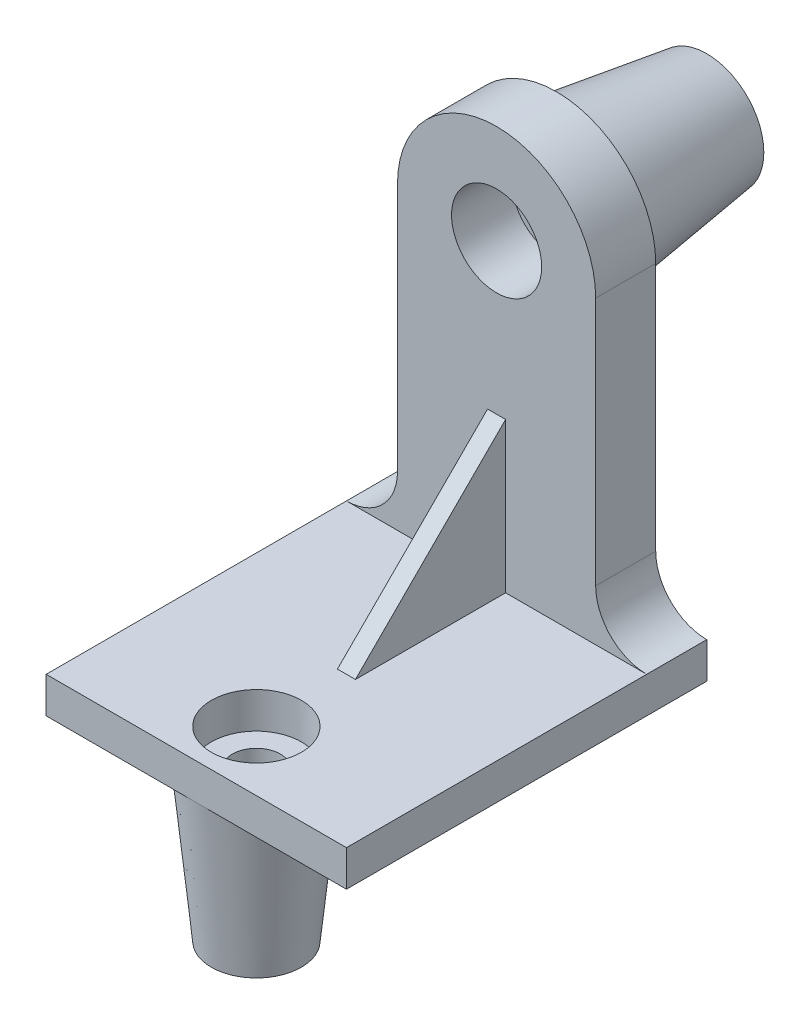
from build123d import *

# Parameters (mm, degrees)
CROQUIS2_R              = 15
SALIENTE_EXTRUIR1_DEPTH = 20
CROQUIS5_R              = 26
CROQUIS4_R              = 19
CORTAR_EXTRUIR1_REACH   = 160.887
CROQUIS4_7_R            = 10
SALIENTE_EXTRUIR2_REACH = 176.396
CROQUIS8_W              = 100
CROQUIS8_H              = 20
CROQUIS9_W              = 100
CROQUIS9_H              = 12
SALIENTE_EXTRUIR3_DEPTH = 125
CROQUIS11_W             = 6
CROQUIS11_H             = 50
SALIENTE_EXTRUIR4_DEPTH = 50
CORTAR_EXTRUIR2_DEPTH   = 50
CORTAR_EXTRUIR3_REACH   = 215.549
CROQUIS13_R             = 15
CORTAR_EXTRUIR4_REACH   = 215.549
CROQUIS18_W             = 100
CROQUIS18_H             = 25
CROQUIS20_R             = 20
CROQUIS15_R             = 15
CORTAR_EXTRUIR5_REACH   = 245.545
CROQUIS22_R             = 8


with BuildPart() as part:
    # Croquis2 → Saliente-Extruir1 (new body)
    with BuildSketch(Plane.XY):
        with BuildLine():
            Line((-66, 83), (-66, 0))
            ThreePointArc((-66, 0), (-70.97918472, -12.02081528), (-83, -17))
            Line((-83, -17), (17, -17))
            ThreePointArc((17, -17), (4.97918472, -12.02081528), (0, 0))
            Line((0, 0), (0, 83))
            ThreePointArc((0, 83), (-33, 116), (-66, 83))
        make_face()
        with Locations((-33, 83)):
            Circle(CROQUIS2_R, mode=Mode.SUBTRACT)
    extrude(amount=SALIENTE_EXTRUIR1_DEPTH)

    # Croquis5 → Recubrir2 section 0
    with BuildSketch(Plane(origin=(0, 0, 0), x_dir=(-1, 0, 0), z_dir=(0, 0, -1))):
        with Locations((33, 83)):
            Circle(CROQUIS5_R)
    # Croquis4 → Recubrir2 section 1
    with BuildSketch(Plane.XY.offset(-50)):
        with Locations((-33, 83)):
            Circle(CROQUIS4_R)
    loft()

    # Croquis4_7 → Cortar-Extruir1 (cut, up to next)
    with BuildSketch(Plane.XY.offset(-50), mode=Mode.PRIVATE) as cortar_extruir1_sk1:
        with Locations((-33, 83)):
            Circle(CROQUIS4_7_R)
    cortar_extruir1_tool1 = extrude(cortar_extruir1_sk1.sketch, amount=CORTAR_EXTRUIR1_REACH, mode=Mode.PRIVATE) & part.part
    add(cortar_extruir1_tool1.solids().sort_by_distance((-33, 83, -50))[0], mode=Mode.SUBTRACT)

    # Croquis8 → Saliente-Extruir2 (add, up to next)
    with BuildSketch(Plane(origin=(0, -29, 0), x_dir=(1, 0, 0), z_dir=(0, 1, 0)), mode=Mode.PRIVATE) as saliente_extruir2_sk1:
        with Locations((-33, -10)):
            Rectangle(CROQUIS8_W, CROQUIS8_H)
    saliente_extruir2_tool1 = extrude(saliente_extruir2_sk1.sketch, amount=SALIENTE_EXTRUIR2_REACH, mode=Mode.PRIVATE) - part.part
    add(saliente_extruir2_tool1.solids().sort_by_distance((-33, -29, 10))[0])

    # Croquis9 → Saliente-Extruir3 (add)
    with BuildSketch(Plane.XY.offset(20)):
        with Locations((-33, -23)):
            Rectangle(CROQUIS9_W, CROQUIS9_H)
    extrude(amount=SALIENTE_EXTRUIR3_DEPTH)

    # Croquis11 → Saliente-Extruir4 (add)
    with BuildSketch(Plane.XY.offset(20)):
        with Locations((-33, 8)):
            Rectangle(CROQUIS11_W, CROQUIS11_H)
    extrude(amount=SALIENTE_EXTRUIR4_DEPTH)

    # Croquis12 → Cortar-Extruir2 (cut)
    with BuildSketch(Plane(origin=(-30, 0, 0), x_dir=(0, 0, -1), z_dir=(1, 0, 0))):
        Polygon((-70, -17), (-20, 33), (-70, 33), align=None)
    extrude(amount=-CORTAR_EXTRUIR2_DEPTH, mode=Mode.SUBTRACT)

    # Croquis13 → Cortar-Extruir3 (cut, up to next)
    with BuildSketch(Plane(origin=(0, -17, 0), x_dir=(1, 0, 0), z_dir=(0, 1, 0)), mode=Mode.PRIVATE) as cortar_extruir3_sk1:
        with Locations((-33, -100)):
            Circle(CROQUIS13_R)
    cortar_extruir3_tool1 = extrude(cortar_extruir3_sk1.sketch, amount=-CORTAR_EXTRUIR3_REACH, mode=Mode.PRIVATE) & part.part
    add(cortar_extruir3_tool1.solids().sort_by_distance((-33, -17, 100))[0], mode=Mode.SUBTRACT)

    # Croquis18 → Cortar-Extruir4 (cut, up to next)
    with BuildSketch(Plane(origin=(0, -17, 0), x_dir=(1, 0, 0), z_dir=(0, 1, 0)), mode=Mode.PRIVATE) as cortar_extruir4_sk1:
        with Locations((-33, -132.5)):
            Rectangle(CROQUIS18_W, CROQUIS18_H)
    cortar_extruir4_tool1 = extrude(cortar_extruir4_sk1.sketch, amount=-CORTAR_EXTRUIR4_REACH, mode=Mode.PRIVATE) & part.part
    add(cortar_extruir4_tool1.solids().sort_by_distance((-33, -17, 132.5))[0], mode=Mode.SUBTRACT)

    # Croquis20 → Recubrir6 section 0
    with BuildSketch(Plane.XZ.offset(29)):
        with Locations((-33, 100)):
            Circle(CROQUIS20_R)
    # Croquis15 → Recubrir6 section 1
    with BuildSketch(Plane(origin=(0, -79, 0), x_dir=(1, 0, 0), z_dir=(0, 1, 0))):
        with Locations((-33, -100)):
            Circle(CROQUIS15_R)
    loft()

    # Croquis22 → Cortar-Extruir5 (cut, up to next)
    with BuildSketch(Plane.XZ.offset(79), mode=Mode.PRIVATE) as cortar_extruir5_sk1:
        with Locations((-33, 100)):
            Circle(CROQUIS22_R)
    cortar_extruir5_tool1 = extrude(cortar_extruir5_sk1.sketch, amount=-CORTAR_EXTRUIR5_REACH, mode=Mode.PRIVATE) & part.part
    add(cortar_extruir5_tool1.solids().sort_by_distance((-33, -79, 100))[0], mode=Mode.SUBTRACT)


solid = part.part
